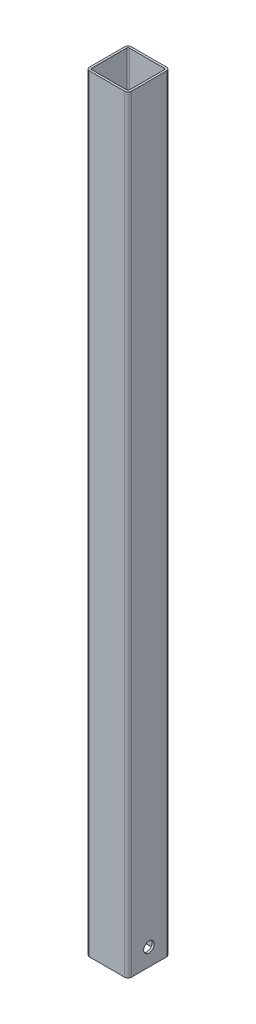
from build123d import *

# Parameters (mm, degrees)
EXTRUDE_1_DEPTH     = 1100
SKETCH_2_R          = 7.5
CUT_EXTRUDE_1_DEPTH = 61


with BuildPart() as part:
    # Эскиз1 → Вытянуть-Тонкостенный1 (new body)
    with BuildSketch(Plane(origin=(0, 0, 0), x_dir=(1, 0, 0), z_dir=(0, 1, 0))):
        with BuildLine():
            Line((-25, 30), (25, 30))
            ThreePointArc((25, 30), (28.535533906, 28.535533906), (30, 25))
            Line((30, 25), (30, -25))
            ThreePointArc((30, -25), (28.535533906, -28.535533906), (25, -30))
            Line((25, -30), (-25, -30))
            ThreePointArc((-25, -30), (-28.535533906, -28.535533906), (-30, -25))
            Line((-30, -25), (-30, 25))
            ThreePointArc((-30, 25), (-28.535533906, 28.535533906), (-25, 30))
        make_face()
        with BuildLine():
            Line((-25, 27), (25, 27))
            ThreePointArc((25, 27), (26.414213562, 26.414213562), (27, 25))
            Line((27, 25), (27, -25))
            ThreePointArc((27, -25), (26.414213562, -26.414213562), (25, -27))
            Line((25, -27), (-25, -27))
            ThreePointArc((-25, -27), (-26.414213562, -26.414213562), (-27, -25))
            Line((-27, -25), (-27, 25))
            ThreePointArc((-27, 25), (-26.414213562, 26.414213562), (-25, 27))
        make_face(mode=Mode.SUBTRACT)
    extrude(amount=EXTRUDE_1_DEPTH)

    # Эскиз2 → Вырез-Вытянуть1 (cut, through all)
    with BuildSketch(Plane(origin=(30, 0, 0), x_dir=(0, 0, -1), z_dir=(1, 0, 0))):
        with Locations((0, 25)):
            Circle(SKETCH_2_R)
    extrude(amount=-CUT_EXTRUDE_1_DEPTH, mode=Mode.SUBTRACT)


solid = part.part
